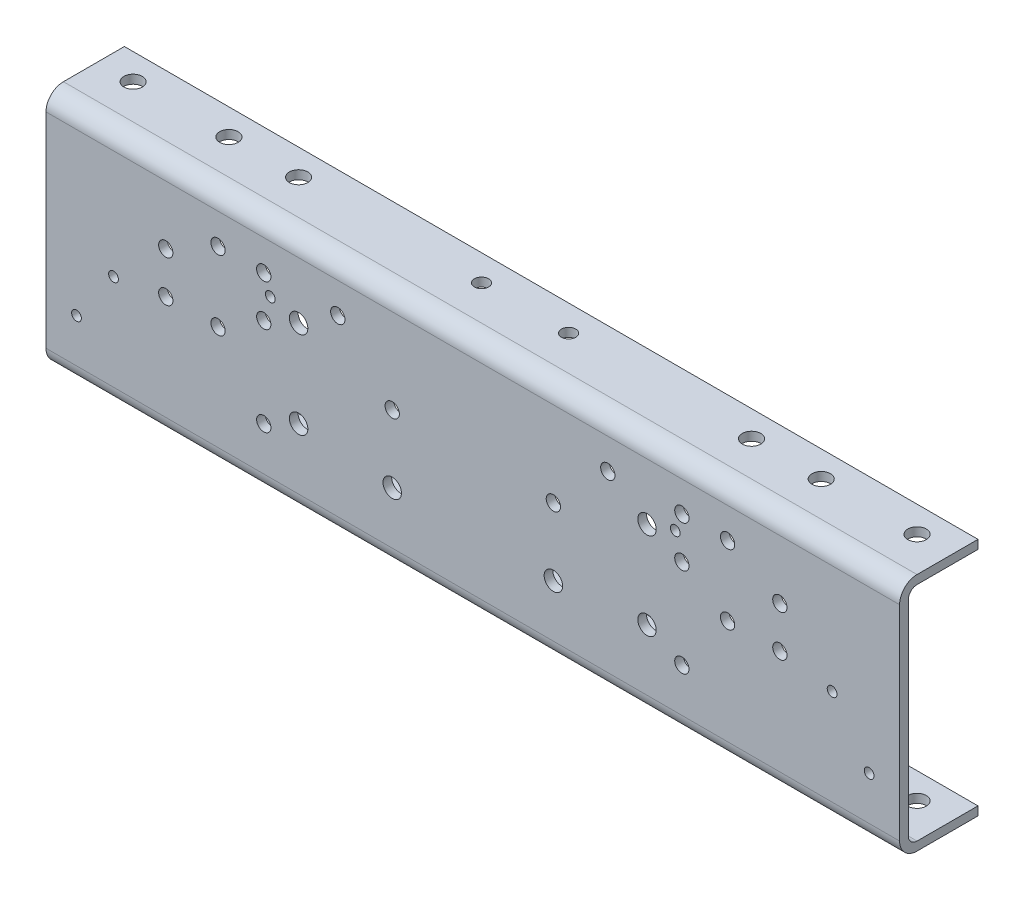
from build123d import *

# Parameters (mm, degrees)
EXTRUDE1_DEPTH           = 311.15
SKETCH2_R                = 5.207
SKETCH2_R_2              = 3.556
SKETCH2_R_3              = 6.731
CUT_WEB_HOLES_DEPTH      = 329.182750394
SKETCH3_R                = 6.731
SKETCH3_R_2              = 5.207
CUT_FLG_HOLES_DEPTH      = 329.182750394
CUT_FLG_HOLES_DEPTH_BACK = 329.182750394
SKETCH6_R                = 5.207
VLV_MODULATOR_DEPTH      = 329.182750394


with BuildPart() as part:
    # Sketch1 → Extrude1 (new, symmetric)
    with BuildSketch(Plane(origin=(0, 0, 0), x_dir=(0, 0, -1), z_dir=(1, 0, 0))):
        with BuildLine():
            Line((57.15, 87.3125), (12.7, 87.3125))
            ThreePointArc((12.7, 87.3125), (3.719743879, 83.592756121), (0, 74.6125))
            Line((0, 74.6125), (0, -74.6125))
            ThreePointArc((0, -74.6125), (3.719743879, -83.592756121), (12.7, -87.3125))
            Line((12.7, -87.3125), (57.15, -87.3125))
            Line((57.15, -87.3125), (57.15, -80.9625))
            Line((57.15, -80.9625), (12.7, -80.9625))
            ThreePointArc((12.7, -80.9625), (8.209871939, -79.102628061), (6.35, -74.6125))
            Line((6.35, -74.6125), (6.35, 74.6125))
            ThreePointArc((6.35, 74.6125), (8.209871939, 79.102628061), (12.7, 80.9625))
            Line((12.7, 80.9625), (57.15, 80.9625))
            Line((57.15, 80.9625), (57.15, 87.3125))
        make_face()
    extrude(amount=EXTRUDE1_DEPTH, both=True)

    # Sketch2 → Cut-Web Holes (cut, through all)
    with BuildSketch(Plane.XY):
        with Locations((-185.7375, 52.3875)):
            Circle(SKETCH2_R)
        with Locations((-261.9375, -4.7625)):
            Circle(SKETCH2_R_2)
        with Locations((-288.925, -42.8625)):
            Circle(SKETCH2_R_2)
        with Locations((-152.4, -42.8625)):
            Circle(SKETCH2_R)
        with Locations((-127, -30.1625)):
            Circle(SKETCH2_R_3)
        with Locations((-127, 33.3375)):
            Circle(SKETCH2_R_3)
        with Locations((-98.425, 52.3875)):
            Circle(SKETCH2_R)
        with Locations((-58.7375, 12.7)):
            Circle(SKETCH2_R)
        with Locations((-58.7375, -36.5125)):
            Circle(SKETCH2_R_3)
        with Locations((-185.7375, 1.5875)):
            Circle(SKETCH2_R)
        with Locations((-147.6375, 39.6875)):
            Circle(SKETCH2_R_2)
        with Locations((147.6375, 39.6875)):
            Circle(SKETCH2_R_2)
        with Locations((98.425, 52.3875)):
            Circle(SKETCH2_R)
        with Locations((127, 33.3375)):
            Circle(SKETCH2_R_3)
        with Locations((185.7375, 52.3875)):
            Circle(SKETCH2_R)
        with Locations((185.7375, 1.5875)):
            Circle(SKETCH2_R)
        with Locations((261.9375, -4.7625)):
            Circle(SKETCH2_R_2)
        with Locations((288.925, -42.8625)):
            Circle(SKETCH2_R_2)
        with Locations((152.4, -42.8625)):
            Circle(SKETCH2_R)
        with Locations((127, -30.1625)):
            Circle(SKETCH2_R_3)
        with Locations((58.7375, 12.7)):
            Circle(SKETCH2_R)
        with Locations((58.7375, -36.5125)):
            Circle(SKETCH2_R_3)
    extrude(amount=-CUT_WEB_HOLES_DEPTH, mode=Mode.SUBTRACT)

    # Sketch3 → Cut-Flg Holes (cut, two sides)
    with BuildSketch(Plane(origin=(0, 0, 0), x_dir=(1, 0, 0), z_dir=(0, 1, 0))) as cut_flg_holes_sk:
        with Locations(Location((-285.75, 38.1, 0), (0, 0, 270))):
            Circle(SKETCH3_R)
        with Locations(Location((-215.9, 38.1, 0), (0, 0, 270))):
            Circle(SKETCH3_R)
        with Locations(Location((285.75, 38.1, 0), (0, 0, 90))):
            Circle(SKETCH3_R)
        with Locations(Location((215.9, 38.1, 0), (0, 0, 90))):
            Circle(SKETCH3_R)
        with Locations(Location((165.1, 38.1, 0), (0, 0, 270))):
            Circle(SKETCH3_R)
        with Locations(Location((31.75, 38.1, 0), (0, 0, 270))):
            Circle(SKETCH3_R_2)
        with Locations(Location((-31.75, 38.1, 0), (0, 0, 270))):
            Circle(SKETCH3_R_2)
        with Locations(Location((-165.1, 38.1, 0), (0, 0, 270))):
            Circle(SKETCH3_R)
    extrude(amount=CUT_FLG_HOLES_DEPTH, mode=Mode.SUBTRACT)
    extrude(cut_flg_holes_sk.sketch, amount=-CUT_FLG_HOLES_DEPTH_BACK, mode=Mode.SUBTRACT)

    # Sketch6 → VLV-MODULATOR (cut, through all)
    with BuildSketch(Plane.XY):
        with Locations((-152.4, 52.3875)):
            Circle(SKETCH6_R)
        with Locations((-223.8375, 31.75)):
            Circle(SKETCH6_R)
        with Locations((-152.4, 22.225)):
            Circle(SKETCH6_R)
        with Locations((-223.8375, 1.5875)):
            Circle(SKETCH6_R)
        with Locations((223.8375, 1.5875)):
            Circle(SKETCH6_R)
        with Locations((152.4, 22.225)):
            Circle(SKETCH6_R)
        with Locations((152.4, 52.3875)):
            Circle(SKETCH6_R)
        with Locations((223.8375, 31.75)):
            Circle(SKETCH6_R)
    extrude(amount=-VLV_MODULATOR_DEPTH, mode=Mode.SUBTRACT)


solid = part.part
